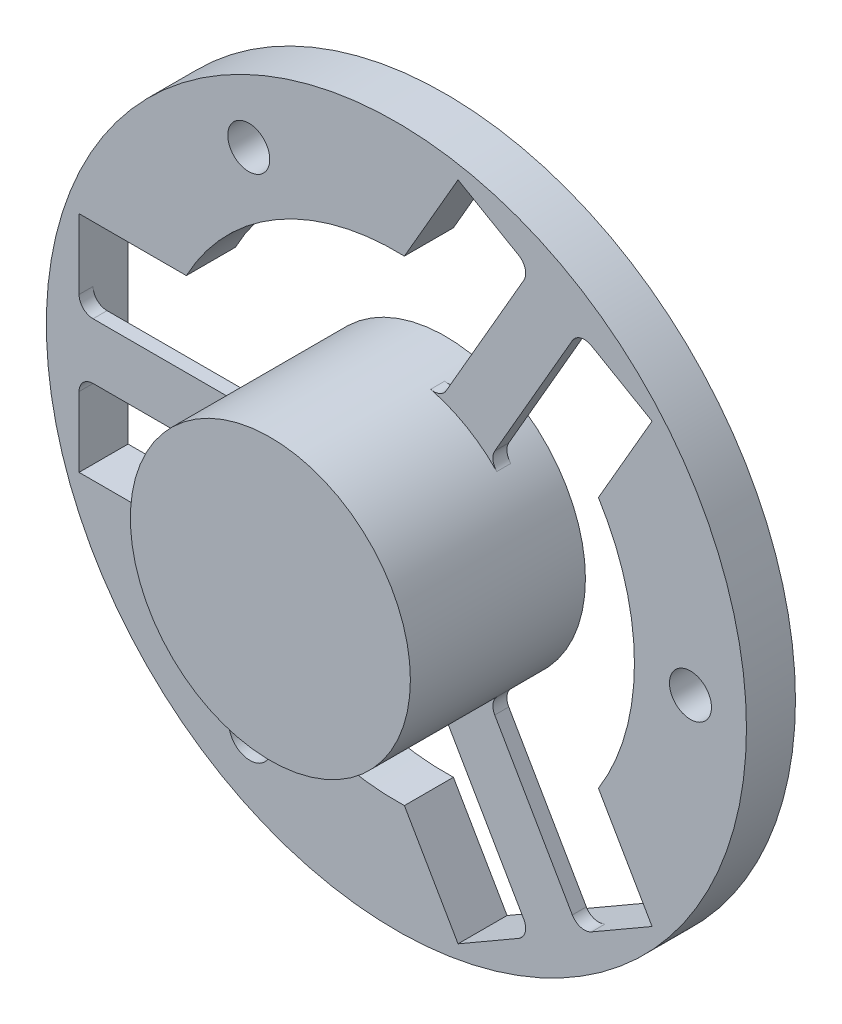
from build123d import *

# Parameters (mm, degrees)
SKETCH1_R                = 10
BOSS_EXTRUDE1_DEPTH      = 9
BOSS_EXTRUDE1_DEPTH_BACK = 3.5
SKETCH1_3_R              = 25
SKETCH1_3_R_2            = 10
BOSS_EXTRUDE2_DEPTH      = 3.5
SKETCH3_R                = 17
CUT_EXTRUDE1_DEPTH       = 3.5
SKETCH8_W                = 9
SKETCH8_H                = 16
CUT_EXTRUDE3_DEPTH       = 4.5
SKETCH10_W               = 12.863801869
SKETCH10_H               = 4
BOSS_EXTRUDE4_DEPTH      = 1
CIRPATTERN2_COUNT        = 3
F_3_0MM_DOWEL_HOLE1_D    = 3
CIRPATTERN3_COUNT        = 3
FILLET1_R                = 1
FILLET2_R                = 1
FILLET3_R                = 1
FILLET4_R                = 1
FILLET5_R                = 1
FILLET6_R                = 1
FILLET7_R                = 1
FILLET8_R                = 1
FILLET9_R                = 1
FILLET10_R               = 1
FILLET11_R               = 1
FILLET12_R               = 1


with BuildPart() as part:
    # Sketch1 → Boss-Extrude1 (new body, two sides)
    with BuildSketch(Plane.XY) as boss_extrude1_sk:
        Circle(SKETCH1_R)
    extrude(amount=BOSS_EXTRUDE1_DEPTH)
    extrude(boss_extrude1_sk.sketch, amount=-BOSS_EXTRUDE1_DEPTH_BACK)



with BuildPart() as body_2:
    # Sketch1_3 → Boss-Extrude2 (new body)
    with BuildSketch(Plane.XY):
        Circle(SKETCH1_3_R)
        Circle(SKETCH1_3_R_2, mode=Mode.SUBTRACT)
    extrude(amount=-BOSS_EXTRUDE2_DEPTH)

    # Sketch3 → Cut-Extrude1 (cut)
    with BuildSketch(Plane.XY):
        Circle(SKETCH3_R)
    extrude(amount=-CUT_EXTRUDE1_DEPTH, mode=Mode.SUBTRACT)

    # Sketch8 → Cut-Extrude3 (cut, through all)
    with BuildSketch(Plane.XY):
        with Locations((-18.16176084, 0)):
            Rectangle(SKETCH8_W, SKETCH8_H)
    cut_extrude3 = extrude(amount=-CUT_EXTRUDE3_DEPTH, mode=Mode.SUBTRACT)


with BuildPart() as part_1:
    add(part.part)

    add(body_2.part)  # Boss-Extrude4 merges body 2
    # Sketch10 → Boss-Extrude4 (add)
    with BuildSketch(Plane.XY):
        with Locations((-16.229859905, 0)):
            Rectangle(SKETCH10_W, SKETCH10_H)
    boss_extrude4 = extrude(amount=-BOSS_EXTRUDE4_DEPTH)

    # CirPattern2: Cut-Extrude3, Boss-Extrude4 ×3 about axis
    cirpattern2_axis = Axis((0, 0, 0), (0, 0, 1))
    for i in range(1, CIRPATTERN2_COUNT):
        add(cut_extrude3.rotate(cirpattern2_axis, i * 360 / CIRPATTERN2_COUNT), mode=Mode.SUBTRACT)
        add(boss_extrude4.rotate(cirpattern2_axis, i * 360 / CIRPATTERN2_COUNT))

    # Ø3.0mm Dowel Hole1 (through all)
    with Locations(Plane.XY):
        with Locations((-10.544029887, 18.161041648)):
            f_3_0mm_dowel_hole1 = Hole(F_3_0MM_DOWEL_HOLE1_D / 2)

    # CirPattern3: Ø3.0mm Dowel Hole1 ×3 about axis
    cirpattern3_axis = Axis((0, 0, 0), (0, 0, 1))
    for i in range(1, CIRPATTERN3_COUNT):
        add(f_3_0mm_dowel_hole1.rotate(cirpattern3_axis, i * 360 / CIRPATTERN3_COUNT), mode=Mode.SUBTRACT)

    # Fillet1
    fillet1_edges = [part_1.edges().sort_by_distance(p)[0] for p in [
        (9.598829613, 20.625660582, -0.5),
    ]]
    fillet(fillet1_edges, radius=FILLET1_R)

    # Fillet2
    fillet2_edges = [part_1.edges().sort_by_distance(p)[0] for p in [
        (13.062931228, 18.625660582, -0.5),
    ]]
    fillet(fillet2_edges, radius=FILLET2_R)

    # Fillet3
    fillet3_edges = [part_1.edges().sort_by_distance(p)[0] for p in [
        (6.631030293, 7.485281374, -0.5),
    ]]
    fillet(fillet3_edges, radius=FILLET3_R)

    # Fillet4
    fillet4_edges = [part_1.edges().sort_by_distance(p)[0] for p in [
        (3.166928678, 9.485281374, -0.5),
    ]]
    fillet(fillet4_edges, radius=FILLET4_R)

    # Fillet5
    fillet5_edges = [part_1.edges().sort_by_distance(p)[0] for p in [
        (-22.66176084, 2, -0.5),
    ]]
    fillet(fillet5_edges, radius=FILLET5_R)

    # Fillet6
    fillet6_edges = [part_1.edges().sort_by_distance(p)[0] for p in [
        (-9.797958971, 2, -0.5),
    ]]
    fillet(fillet6_edges, radius=FILLET6_R)

    # Fillet7
    fillet7_edges = [part_1.edges().sort_by_distance(p)[0] for p in [
        (-22.66176084, -2, -0.5),
    ]]
    fillet(fillet7_edges, radius=FILLET7_R)

    # Fillet8
    fillet8_edges = [part_1.edges().sort_by_distance(p)[0] for p in [
        (-9.797958971, -2, -0.5),
    ]]
    fillet(fillet8_edges, radius=FILLET8_R)

    # Fillet9
    fillet9_edges = [part_1.edges().sort_by_distance(p)[0] for p in [
        (3.166928678, -9.485281374, -0.5),
    ]]
    fillet(fillet9_edges, radius=FILLET9_R)

    # Fillet10
    fillet10_edges = [part_1.edges().sort_by_distance(p)[0] for p in [
        (6.631030293, -7.485281374, -0.5),
    ]]
    fillet(fillet10_edges, radius=FILLET10_R)

    # Fillet11
    fillet11_edges = [part_1.edges().sort_by_distance(p)[0] for p in [
        (9.598829613, -20.625660582, -0.5),
    ]]
    fillet(fillet11_edges, radius=FILLET11_R)

    # Fillet12
    fillet12_edges = [part_1.edges().sort_by_distance(p)[0] for p in [
        (13.062931228, -18.625660582, -0.5),
    ]]
    fillet(fillet12_edges, radius=FILLET12_R)


solid = part_1.part
